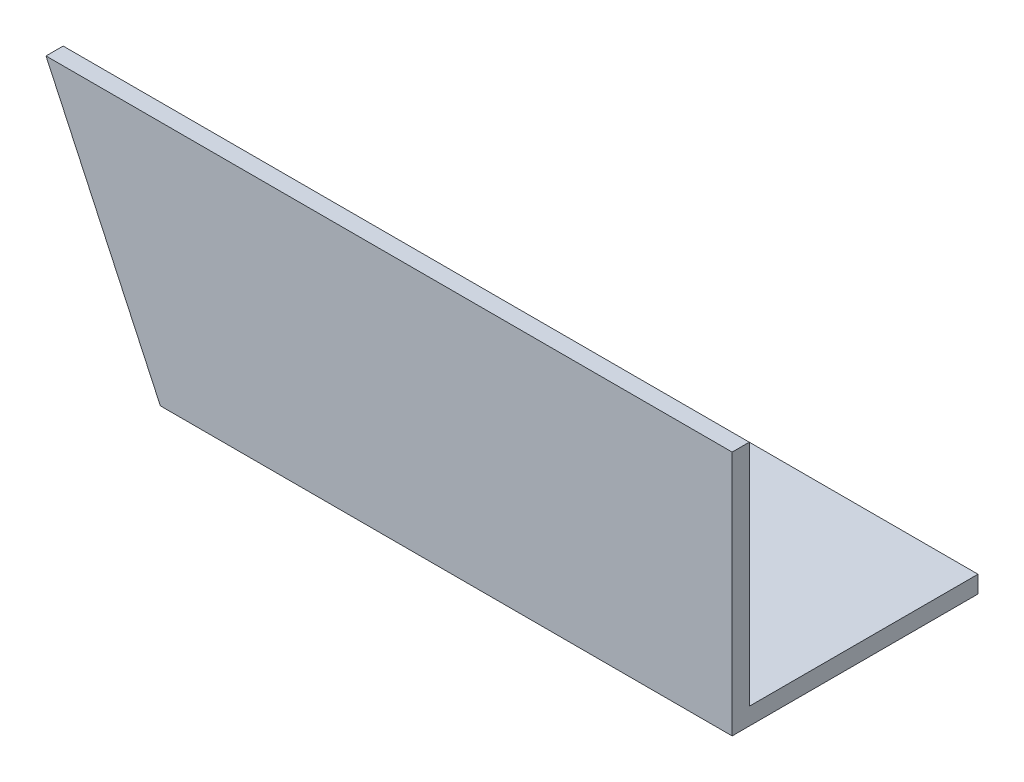
from build123d import *

# Parameters (mm, degrees)
EXTRUDE_1_DEPTH     = 120
CUT_EXTRUDE_1_DEPTH = 50
SKETCH_3_R          = 5
CUT_EXTRUDE_2_DEPTH = 10


with BuildPart() as part:
    # Эскиз1 → Вытянуть-Тонкостенный1 (new body)
    with BuildSketch(Plane(origin=(0, 0, 0), x_dir=(0, 0, -1), z_dir=(1, 0, 0))):
        Polygon((0, 40), (0, 0), (40, 0), (40, -3), (-3, -3), (-3, 40), align=None)
    extrude(amount=EXTRUDE_1_DEPTH)

    # Эскиз2 → Вырез-Вытянуть1 (cut)
    with BuildSketch(Plane.XY.offset(3)):
        Polygon((0, 40), (20, -3), (0, -3), align=None)
    extrude(amount=-CUT_EXTRUDE_1_DEPTH, mode=Mode.SUBTRACT)

    # Эскиз3 → Вырез-Вытянуть2 (cut)
    with BuildSketch(Plane.XZ.offset(3)):
        with Locations((70, -15)):
            Circle(SKETCH_3_R)
    extrude(amount=-CUT_EXTRUDE_2_DEPTH, mode=Mode.SUBTRACT)


solid = part.part
